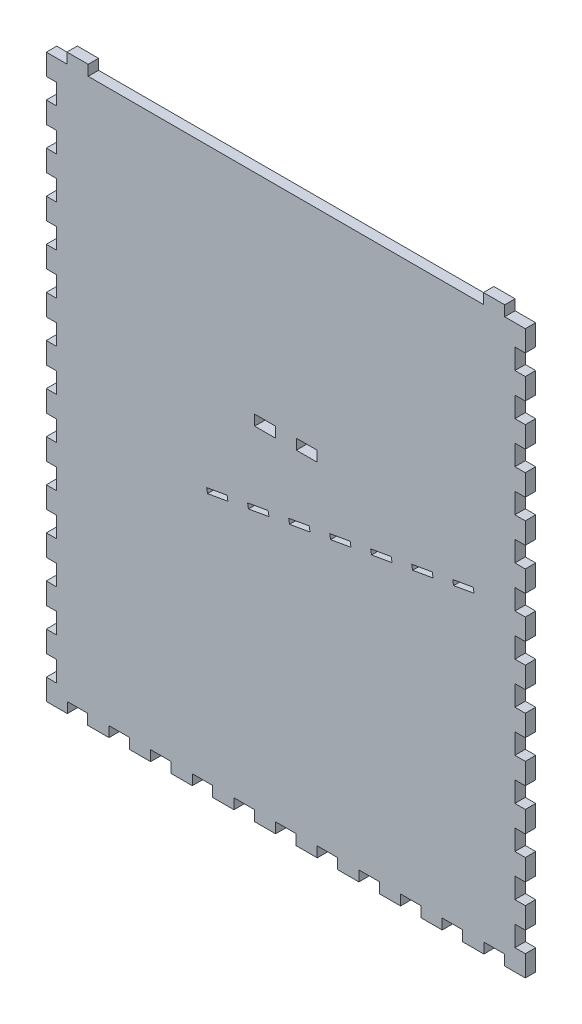
from build123d import *

# Parameters (mm, degrees)
SKETCH1_W           = 12.573
SKETCH1_H           = 6.35
BOSS_EXTRUDE1_DEPTH = 6.35


with BuildPart() as part:
    # Sketch1 → Boss-Extrude1 (new body)
    with BuildSketch(Plane.XY):
        Polygon((0, 0), (12.573, 0), (12.573, 6.35), (25.527, 6.35), (25.527, 0), (266.573, 0), (266.573, 6.35), (279.527, 6.35), (279.527, 0), (292.1, 0), (292.1, -12.827), (285.75, -12.827), (285.75, -25.273), (292.1, -25.273), (292.1, -38.227), (285.75, -38.227), (285.75, -50.673), (292.1, -50.673), (292.1, -63.627), (285.75, -63.627), (285.75, -76.073), (292.1, -76.073), (292.1, -89.027), (285.75, -89.027), (285.75, -101.473), (292.1, -101.473), (292.1, -114.427), (285.75, -114.427), (285.75, -126.873), (292.1, -126.873), (292.1, -139.827), (285.75, -139.827), (285.75, -152.273), (292.1, -152.273), (292.1, -165.227), (285.75, -165.227), (285.75, -177.673), (292.1, -177.673), (292.1, -190.627), (285.75, -190.627), (285.75, -203.073), (292.1, -203.073), (292.1, -216.027), (285.75, -216.027), (285.75, -228.473), (292.1, -228.473), (292.1, -241.427), (285.75, -241.427), (285.75, -253.873), (292.1, -253.873), (292.1, -266.827), (285.75, -266.827), (285.75, -279.273), (292.1, -279.273), (292.1, -292.227), (285.75, -292.227), (285.75, -304.673), (292.1, -304.673), (292.1, -317.627), (285.75, -317.627), (285.75, -330.073), (292.1, -330.073), (292.1, -342.9), (279.273, -342.9), (279.273, -336.55), (266.827, -336.55), (266.827, -342.9), (253.873, -342.9), (253.873, -336.55), (241.427, -336.55), (241.427, -342.9), (228.473, -342.9), (228.473, -336.55), (216.027, -336.55), (216.027, -342.9), (203.073, -342.9), (203.073, -336.55), (190.627, -336.55), (190.627, -342.9), (177.673, -342.9), (177.673, -336.55), (165.227, -336.55), (165.227, -342.9), (152.273, -342.9), (152.273, -336.55), (139.827, -336.55), (139.827, -342.9), (126.873, -342.9), (126.873, -336.55), (114.427, -336.55), (114.427, -342.9), (101.473, -342.9), (101.473, -336.55), (89.027, -336.55), (89.027, -342.9), (76.073, -342.9), (76.073, -336.55), (63.627, -336.55), (63.627, -342.9), (50.673, -342.9), (50.673, -336.55), (38.227, -336.55), (38.227, -342.9), (25.273, -342.9), (25.273, -336.55), (12.827, -336.55), (12.827, -342.9), (0, -342.9), (0, -330.073), (6.35, -330.073), (6.35, -317.627), (0, -317.627), (0, -304.673), (6.35, -304.673), (6.35, -292.227), (0, -292.227), (0, -279.273), (6.35, -279.273), (6.35, -266.827), (0, -266.827), (0, -253.873), (6.35, -253.873), (6.35, -241.427), (0, -241.427), (0, -228.473), (6.35, -228.473), (6.35, -216.027), (0, -216.027), (0, -203.073), (6.35, -203.073), (6.35, -190.627), (0, -190.627), (0, -177.673), (6.35, -177.673), (6.35, -165.227), (0, -165.227), (0, -152.273), (6.35, -152.273), (6.35, -139.827), (0, -139.827), (0, -126.873), (6.35, -126.873), (6.35, -114.427), (0, -114.427), (0, -101.473), (6.35, -101.473), (6.35, -89.027), (0, -89.027), (0, -76.073), (6.35, -76.073), (6.35, -63.627), (0, -63.627), (0, -50.673), (6.35, -50.673), (6.35, -38.227), (0, -38.227), (0, -25.273), (6.35, -25.273), (6.35, -12.827), (0, -12.827), align=None)
        Polygon((260.870458318, -155.351665797), (248.363399855, -157.556997654), (247.842941537, -154.605331856), (260.35, -152.4), align=None, mode=Mode.SUBTRACT)
        Polygon((235.856341392, -159.76232951), (223.349282928, -161.967661366), (222.82882461, -159.015995569), (235.335883073, -156.810663713), align=None, mode=Mode.SUBTRACT)
        with Locations((158.75, -130.81)):
            Rectangle(SKETCH1_W, SKETCH1_H, mode=Mode.SUBTRACT)
        with Locations((133.35, -130.81)):
            Rectangle(SKETCH1_W, SKETCH1_H, mode=Mode.SUBTRACT)
        Polygon((210.842224465, -164.172993223), (198.335166002, -166.378325079), (197.814707684, -163.426659282), (210.321766147, -161.221327425), align=None, mode=Mode.SUBTRACT)
        Polygon((185.828107539, -168.583656936), (173.321049075, -170.788988792), (172.800590757, -167.837322995), (185.30764922, -165.631991138), align=None, mode=Mode.SUBTRACT)
        Polygon((160.813990612, -172.994320648), (148.306932149, -175.199652505), (147.786473831, -172.247986707), (160.293532294, -170.042654851), align=None, mode=Mode.SUBTRACT)
        Polygon((135.799873686, -177.404984361), (123.292815222, -179.610316217), (122.772356904, -176.65865042), (135.279415367, -174.453318564), align=None, mode=Mode.SUBTRACT)
        Polygon((110.785756759, -181.815648074), (98.278698296, -184.02097993), (97.758239978, -181.069314133), (110.265298441, -178.863982276), align=None, mode=Mode.SUBTRACT)
    extrude(amount=BOSS_EXTRUDE1_DEPTH)


solid = part.part
